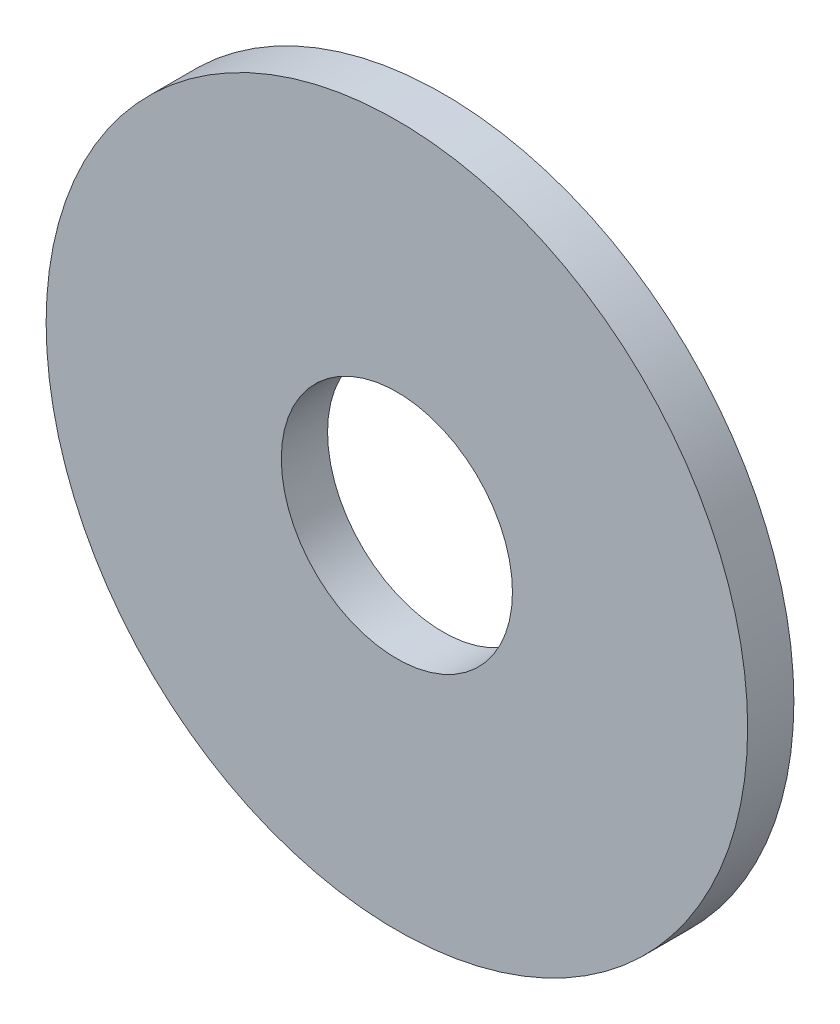
from build123d import *

# Parameters (mm, degrees)
SKETCH1_R           = 7.5875
SKETCH1_R_2         = 2.5
BOSS_EXTRUDE1_DEPTH = 1


with BuildPart() as part:
    # Sketch1 → Boss-Extrude1 (new body)
    with BuildSketch(Plane.XY):
        Circle(SKETCH1_R)
        Circle(SKETCH1_R_2, mode=Mode.SUBTRACT)
    extrude(amount=BOSS_EXTRUDE1_DEPTH)


solid = part.part
